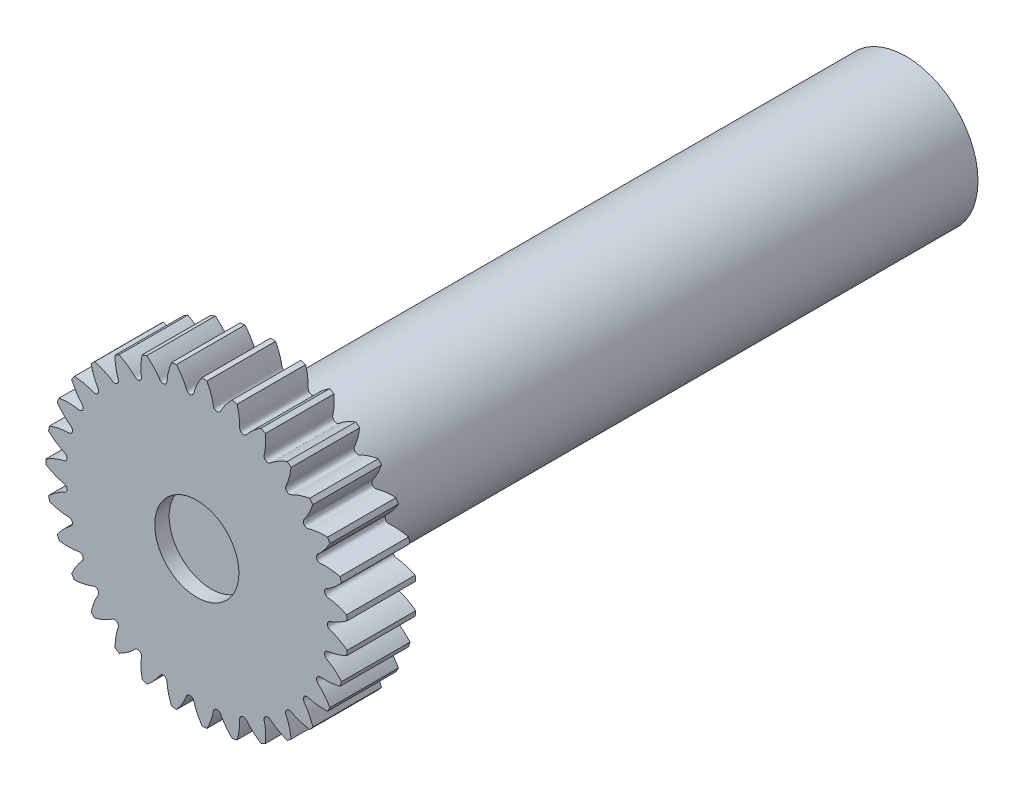
from build123d import *

# Parameters (mm, degrees)
SKETCHREVOLVESPURGEAR_W       = 19.05
SKETCHREVOLVESPURGEAR_H       = 41.909999371
TOOTHEXTRUDECUTSPURGEAR_DEPTH = 9.525
PATTERNSPURGEAR_COUNT         = 31
SCALE1_SCALE                  = 0.5
SKETCH1_R                     = 5.845002224
CUT_EXTRUDE1_DEPTH            = 2
SKETCH3_R                     = 10
BOSS_EXTRUDE1_DEPTH           = 89


with BuildPart() as part:
    # SketchRevolveSpurGear → SpurGear (revolve)
    with BuildSketch(Plane(origin=(0, 0, 0), x_dir=(0, 0, -1), z_dir=(1, 0, 0))):
        with Locations((0, 20.954999686)):
            Rectangle(SKETCHREVOLVESPURGEAR_W, SKETCHREVOLVESPURGEAR_H)
    revolve(axis=Axis((0, 0, 0), (0, 0, -1)))

    # SketchToothSpurGear → ToothExtrudeCutSpurGear (cut, symmetric)
    with BuildSketch(Plane.XY):
        with BuildLine():
            ThreePointArc((41.879828855, 3.631700844), (42.036999369, 0), (41.879828855, -3.631700844))
            add(Edge.make_bspline(
                [(41.879828855, -3.631700844), (41.669093148, -3.473628768), (41.353627061, -3.245633248), (40.931344399, -2.958021229), (40.625762482, -2.757985264), (40.326705221, -2.569951993), (40.034506388, -2.393613207), (39.749490617, -2.228652457), (39.471973203, -2.074745439), (39.202259973, -1.931560077), (38.94064693, -1.798757219), (38.687420732, -1.675989288), (38.44285625, -1.562906106), (38.207224389, -1.459135677), (37.980764125, -1.364352251), (37.763778968, -1.278041091), (37.556302485, -1.200313665), (37.298362463, -1.107094011), (37.082156837, -1.04391756), (36.918130379, -0.971607639), (36.852260919, -0.93892453), (36.786645786, -0.902165044), (36.721044049, -0.86043719), (36.655302397, -0.812584663), (36.589480388, -0.757146516), (36.524026054, -0.692356587), (36.460038785, -0.61624122), (36.399558238, -0.526907647), (36.34586688, -0.42309979), (36.303107179, -0.305060594), (36.278143184, -0.181843931), (36.270196301, -0.078668909), (36.271536843, 0), (36.270196301, 0.078668909), (36.278143184, 0.181843931), (36.303107179, 0.305060594), (36.34586688, 0.42309979), (36.399558238, 0.526907647), (36.460038785, 0.61624122), (36.524026054, 0.692356587), (36.589480388, 0.757146516), (36.655302397, 0.812584663), (36.721044049, 0.86043719), (36.786645786, 0.902165044), (36.852260919, 0.93892453), (36.918130379, 0.971607639), (37.082156837, 1.04391756), (37.298362463, 1.107094011), (37.556302485, 1.200313665), (37.763778968, 1.278041091), (37.980764125, 1.364352251), (38.207224389, 1.459135677), (38.44285625, 1.562906106), (38.687420732, 1.675989288), (38.94064693, 1.798757219), (39.202259973, 1.931560077), (39.471973203, 2.074745439), (39.749490617, 2.228652457), (40.034506388, 2.393613207), (40.326705221, 2.569951993), (40.625762482, 2.757985264), (40.931344399, 2.958021229), (41.353627061, 3.245633248), (41.669093148, 3.473628768), (41.879828855, 3.631700844)],
                knots=[0, 0, 0, 0, 0.057293456, 0.084638179, 0.111114898, 0.136723614, 0.161464327, 0.185337037, 0.208341743, 0.230478446, 0.251747145, 0.272147841, 0.291680534, 0.310345223, 0.328141909, 0.345070592, 0.361131271, 0.376323947, 0.404732018, 0.409978373, 0.415290301, 0.420719481, 0.426328108, 0.432190116, 0.438391348, 0.445027287, 0.45219614, 0.459984311, 0.468442064, 0.477551385, 0.487197085, 0.495694033, 0.5, 0.504305967, 0.512802915, 0.522448615, 0.531557936, 0.540015689, 0.54780386, 0.554972713, 0.561608652, 0.567809884, 0.573671892, 0.579280519, 0.584709699, 0.590021627, 0.595267982, 0.623676053, 0.638868729, 0.654929408, 0.671858091, 0.689654777, 0.708319466, 0.727852159, 0.748252855, 0.769521554, 0.791658257, 0.814662963, 0.838535673, 0.863276386, 0.888885102, 0.915361821, 0.942706544, 1, 1, 1, 1], degree=3))
        make_face()
    toothextrudecutspurgear = extrude(amount=TOOTHEXTRUDECUTSPURGEAR_DEPTH, both=True, mode=Mode.SUBTRACT)

    # PatternSpurGear: ToothExtrudeCutSpurGear ×31 about axis
    patternspurgear_axis = Axis((0, 0, 10.4775), (0, 0, -1))
    for i in range(1, PATTERNSPURGEAR_COUNT):
        add(toothextrudecutspurgear.rotate(patternspurgear_axis, i * 360 / PATTERNSPURGEAR_COUNT), mode=Mode.SUBTRACT)


with BuildPart() as part_1:
    # Scale1: scaled about (0, 0, 0)
    add(part.part.scale(SCALE1_SCALE))

    # Sketch1 → Cut-Extrude1 (cut)
    with BuildSketch(Plane.XY.offset(4.7625)):
        Circle(SKETCH1_R)
    extrude(amount=-CUT_EXTRUDE1_DEPTH, mode=Mode.SUBTRACT)

    # Sketch3 → Boss-Extrude1 (add)
    with BuildSketch(Plane(origin=(0, 0, -4.7625), x_dir=(-1, 0, 0), z_dir=(0, 0, -1))):
        Circle(SKETCH3_R)
    extrude(amount=BOSS_EXTRUDE1_DEPTH)


solid = part_1.part
